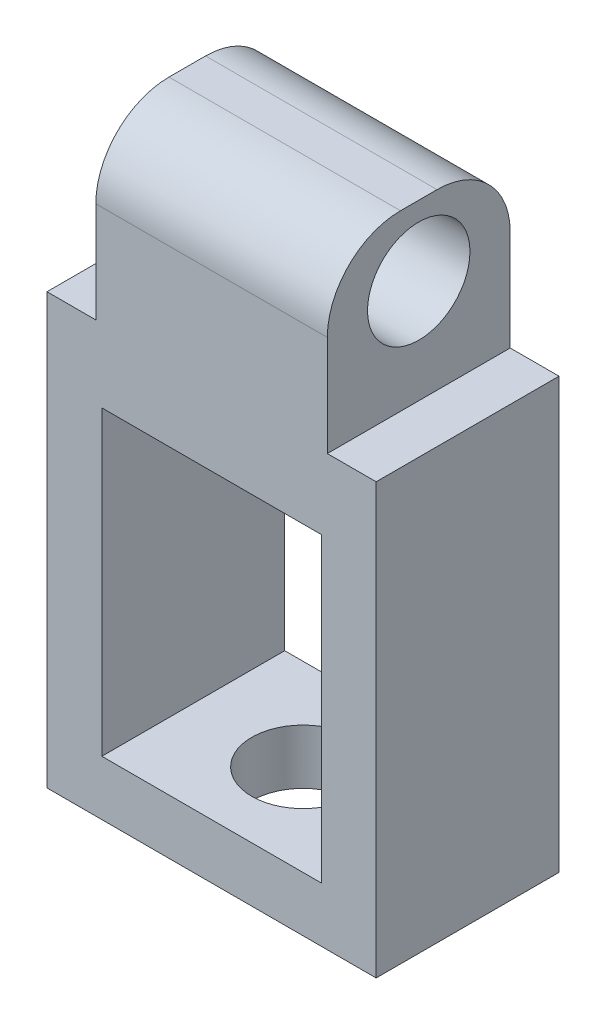
from build123d import *

# Parameters (mm, degrees)
BOSS_EXTRUDE1_DEPTH = 5
SKETCH2_R           = 1.4
CUT_EXTRUDE1_DEPTH  = 8
SKETCH3_R           = 1.4
CUT_EXTRUDE2_DEPTH  = 6
FILLET1_R           = 2


with BuildPart() as part:
    # Sketch1 → Boss-Extrude1 (new body)
    with BuildSketch(Plane.XY):
        Polygon((-12.363085779, 11.239336475), (-6.033085779, 11.239336475), (-6.033085779, 6.489336475), (-4.698085779, 6.489336475), (-4.698085779, -5.260663525), (-13.698085779, -5.260663525), (-13.698085779, 6.489336475), (-12.363085779, 6.489336475), align=None)
        Polygon((-9.198085779, 4.489336475), (-6.198085779, 4.489336475), (-6.198085779, -3.760663525), (-12.198085779, -3.760663525), (-12.198085779, 4.489336475), align=None, mode=Mode.SUBTRACT)
    extrude(amount=BOSS_EXTRUDE1_DEPTH)

    # Sketch2 → Cut-Extrude1 (cut)
    with BuildSketch(Plane(origin=(-6.033085779, 0, 0), x_dir=(0, 0, -1), z_dir=(1, 0, 0))):
        with Locations((-2.5, 9.323502588)):
            Circle(SKETCH2_R)
    extrude(amount=-CUT_EXTRUDE1_DEPTH, mode=Mode.SUBTRACT)

    # Sketch3 → Cut-Extrude2 (cut)
    with BuildSketch(Plane.XZ.offset(5.260663525)):
        with Locations((-9.198085779, 2.5)):
            Circle(SKETCH3_R)
    extrude(amount=-CUT_EXTRUDE2_DEPTH, mode=Mode.SUBTRACT)

    # Fillet1
    fillet1_edges = [part.edges().sort_by_distance(p)[0] for p in [
        (-9.198085779, 11.239336475, 5),
        (-9.198085779, 11.239336475, 0),
    ]]
    fillet(fillet1_edges, radius=FILLET1_R)


solid = part.part
